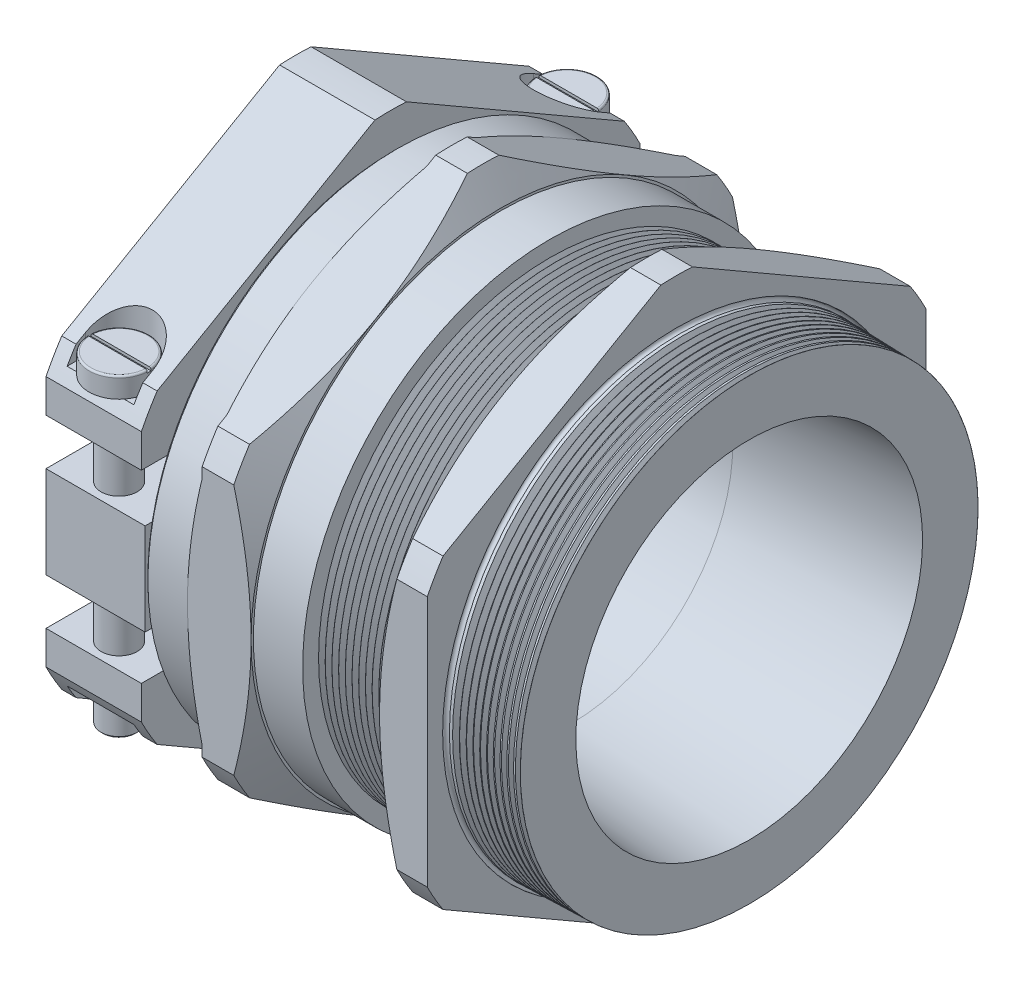
from build123d import *

# Parameters (mm, degrees)
SKETCH1_W            = 13.0175
SKETCH1_H            = 16.14932
SKETCH2_OUTSIDE_W    = 103.11
SKETCH2_OUTSIDE_H    = 103.11
CUT_EXTRUDE1_DEPTH   = 52.0446
SKETCH13_OUTSIDE_W   = 154.302
SKETCH13_OUTSIDE_H   = 162.47
SKETCH13_OUTSIDE_R   = 34.036
CUT1_DEPTH           = 17.41475
CUT1_DRAFT           = 60
SKETCH14_OUTSIDE_W   = 194.398
SKETCH14_OUTSIDE_H   = 202.566
SKETCH14_OUTSIDE_R   = 34.036
CUT2_DEPTH           = 28.989388889
CUT2_DRAFT           = -60
SKETCH15_OUTSIDE_W   = 100.904
SKETCH15_OUTSIDE_H   = 109.072
SKETCH15_OUTSIDE_R   = 34.036
CUT3_DEPTH           = 2
CUT3_DRAFT           = -60
CHAMFER1_SIZE        = 0.381
SKETCH3_W            = 68.072
SKETCH3_H            = 25.1968
CUT_EXTRUDE2_DEPTH   = 13.0175
EXTRUDE1_DEPTH       = 13.5255
CUT_EXTRUDE3_DEPTH   = 20.22272
MIRROR2_COPY_1_DEPTH = 20.22272
SKETCH6_R            = 4.1005125
EXTRUDE2_DEPTH       = 2.757269
SKETCH7_R            = 2.4603075
EXTRUDE3_DEPTH       = 34.995555556
CUT_EXTRUDE4_DEPTH   = 0.381
FILLET1_R            = 0.254
FILLET1_OF_MIRROR3_R = 0.254
LPATTERN1_COUNT      = 12
LPATTERN1_PITCH      = 0.9144
LPATTERN2_COUNT      = 10
LPATTERN2_PITCH      = 0.9144
SKETCH17_W           = 5.023555556
SKETCH17_H           = 6.5913
SKETCH16_R           = 0.4445
CHAMFER2_SIZE        = 0.254


with BuildPart() as part:
    # Sketch1 → Revolve1 (revolve)
    with BuildSketch(Plane.XY, mode=Mode.PRIVATE) as revolve1_sk:
        Polygon((24.21255, 23.664106431), (24.21255, 31.237267383), (14.33195, 31.496), (14.33195, 31.5468), (14.30655, 31.5468), (14.30655, 38.12032), (7.7978, 38.12032), (7.7978, 31.5468), (-3.024716667, 31.5468), (-3.024716667, 33.7185), (-9.748661111, 33.7185), (-9.748661111, 38.12032), (-18.426994444, 38.12032), (-18.426994444, 34.036), (-24.21255, 34.036), (-24.21255, 28.5623), (-18.426994444, 28.5623), (-18.426994444, 21.971), (0, 21.971), align=None)
        with Locations((-31.2293, 30.04566)):
            Rectangle(SKETCH1_W, SKETCH1_H)
    revolve(revolve1_sk.sketch.rotate(Axis((-81.490075188, 0, 0), (1, 0, 0)), 180), axis=Axis((-81.490075188, 0, 0), (1, 0, 0)))  # turned: the seam where the file's is

    # Sketch2 outside → Cut-Extrude1 (cut)
    with BuildSketch(Plane(origin=(14.30655, 0, 0), x_dir=(0, 0, -1), z_dir=(1, 0, 0))):
        Rectangle(SKETCH2_OUTSIDE_W, SKETCH2_OUTSIDE_H)
        with BuildLine():
            Line((-2.150850789, 38.059593243), (-31.885149211, 20.892488044))
            ThreePointArc((-31.885149211, 20.892488044), (-33.01316552, 19.06016), (-34.036, 17.167105199))
            Line((-34.036, 17.167105199), (-34.036, -17.167105199))
            ThreePointArc((-34.036, -17.167105199), (-33.01316552, -19.06016), (-31.885149211, -20.892488044))
            Line((-31.885149211, -20.892488044), (-2.150850789, -38.059593243))
            ThreePointArc((-2.150850789, -38.059593243), (0, -38.12032), (2.150850789, -38.059593243))
            Line((2.150850789, -38.059593243), (31.885149211, -20.892488044))
            ThreePointArc((31.885149211, -20.892488044), (33.01316552, -19.06016), (34.036, -17.167105199))
            Line((34.036, -17.167105199), (34.036, 17.167105199))
            ThreePointArc((34.036, 17.167105199), (33.01316552, 19.06016), (31.885149211, 20.892488044))
            Line((31.885149211, 20.892488044), (2.150850789, 38.059593243))
            ThreePointArc((2.150850789, 38.059593243), (0, 38.12032), (-2.150850789, 38.059593243))
        make_face(mode=Mode.SUBTRACT)
    extrude(amount=-CUT_EXTRUDE1_DEPTH, mode=Mode.SUBTRACT)


with BuildPart() as cut1_tool:
    # Sketch13 outside → Cut1 (with draft: the straight prism first)
    with BuildSketch(Plane(origin=(7.7978, 0, 0), x_dir=(0, 0, -1), z_dir=(1, 0, 0))):
        Rectangle(SKETCH13_OUTSIDE_W, SKETCH13_OUTSIDE_H)
        with Locations(Location((0, 0, 0), (0, 0, 270))):  # turned: the seam where the file's is
            Circle(SKETCH13_OUTSIDE_R, mode=Mode.SUBTRACT)
    extrude(amount=CUT1_DEPTH)
    # Cut1: the draft: its side faces are tilted about the plane it starts from
    cut1_sides = [cut1_tool.faces().sort_by_distance(p)[0] for p in [
        (16.505175, -81.235, 0),
        (16.505175, 0, -77.151),
        (16.505175, 81.235, 0),
        (16.505175, 0, 77.151),
        (16.505175, 34.036, 0),
    ]]
    draft(cut1_sides, Plane(origin=(7.7978, 0, 0), x_dir=(0, 0, -1), z_dir=(1, 0, 0)), CUT1_DRAFT)


with BuildPart() as part_1:
    add(part.part)

    # Cut1: cut by cut1_tool
    add(cut1_tool.part, mode=Mode.SUBTRACT)


with BuildPart() as cut2_tool:
    # Sketch14 outside → Cut2 (with draft: the straight prism first)
    with BuildSketch(Plane(origin=(-9.748661111, 0, 0), x_dir=(0, 0, -1), z_dir=(1, 0, 0))):
        Rectangle(SKETCH14_OUTSIDE_W, SKETCH14_OUTSIDE_H)
        with Locations(Location((0, 0, 0), (0, 0, 270))):  # turned: the seam where the file's is
            Circle(SKETCH14_OUTSIDE_R, mode=Mode.SUBTRACT)
    extrude(amount=-CUT2_DEPTH)
    # Cut2: the draft: its side faces are tilted about the plane it starts from
    cut2_sides = [cut2_tool.faces().sort_by_distance(p)[0] for p in [
        (-24.243355556, -101.283, 0),
        (-24.243355556, 0, -97.199),
        (-24.243355556, 101.283, 0),
        (-24.243355556, 0, 97.199),
        (-24.243355556, 34.036, 0),
    ]]
    draft(cut2_sides, Plane(origin=(-9.748661111, 0, 0), x_dir=(0, 0, -1), z_dir=(1, 0, 0)), CUT2_DRAFT)


with BuildPart() as part_2:
    add(part_1.part)

    # Cut2: cut by cut2_tool
    add(cut2_tool.part, mode=Mode.SUBTRACT)


with BuildPart() as cut3_tool:
    # Sketch15 outside → Cut3 (with draft: the straight prism first)
    with BuildSketch(Plane.ZY.offset(18.426994444)):
        Rectangle(SKETCH15_OUTSIDE_W, SKETCH15_OUTSIDE_H)
        with Locations(Location((0, 0, 0), (0, 0, 270))):  # turned: the seam where the file's is
            Circle(SKETCH15_OUTSIDE_R, mode=Mode.SUBTRACT)
    extrude(amount=-CUT3_DEPTH)
    # Cut3: the draft: its side faces are tilted about the plane it starts from
    cut3_sides = [cut3_tool.faces().sort_by_distance(p)[0] for p in [
        (-17.426994444, -54.536, 0),
        (-17.426994444, 0, 50.452),
        (-17.426994444, 54.536, 0),
        (-17.426994444, 0, -50.452),
        (-17.426994444, 34.036, 0),
    ]]
    draft(cut3_sides, Plane.ZY.offset(18.426994444), CUT3_DRAFT)


with BuildPart() as part_3:
    add(part_2.part)

    # Cut3: cut by cut3_tool
    add(cut3_tool.part, mode=Mode.SUBTRACT)

    # Chamfer1
    chamfer1_edges = [part_3.edges().sort_by_distance(p)[0] for p in [
        (-24.21255, 34.036, 0),
    ]]
    chamfer(chamfer1_edges, length=CHAMFER1_SIZE)

    # Sketch3 → Cut-Extrude2 (cut)
    with BuildSketch(Plane.ZY.offset(37.73805)):
        Rectangle(SKETCH3_W, SKETCH3_H)
    extrude(amount=-CUT_EXTRUDE2_DEPTH, mode=Mode.SUBTRACT)

    # Sketch4 → Extrude1 (add)
    with BuildSketch(Plane.ZY.offset(24.21255)):
        with BuildLine():
            Line((34.036, 6.277428571), (21.055135514, 6.277428571))
            ThreePointArc((21.055135514, 6.277428571), (21.971, 0), (21.055135514, -6.277428571))
            Line((21.055135514, -6.277428571), (34.036, -6.277428571))
            Line((34.036, -6.277428571), (34.036, 6.277428571))
        make_face()
        with BuildLine():
            Line((-34.036, -6.277428571), (-21.055135514, -6.277428571))
            ThreePointArc((-21.055135514, -6.277428571), (-21.971, 0), (-21.055135514, 6.277428571))
            Line((-21.055135514, 6.277428571), (-34.036, 6.277428571))
            Line((-34.036, 6.277428571), (-34.036, -6.277428571))
        make_face()
    extrude(amount=EXTRUDE1_DEPTH)

    # Sketch5 → Cut-Extrude3 (cut, through all)
    with BuildSketch(Plane(origin=(0, -18.8976, 0), x_dir=(1, 0, 0), z_dir=(0, 1, 0))):
        with BuildLine():
            Line((-35.785425, -30.564666667), (-35.785425, -34.036))
            Line((-35.785425, -34.036), (-26.673175, -34.036))
            Line((-26.673175, -34.036), (-26.673175, -30.564666667))
            ThreePointArc((-26.673175, -30.564666667), (-31.2293, -26.008541667), (-35.785425, -30.564666667))
        make_face()
    cut_extrude3 = extrude(amount=-CUT_EXTRUDE3_DEPTH, mode=Mode.SUBTRACT)

    # Mirror1: Cut-Extrude3 across plane
    add(cut_extrude3.mirror(Plane.ZX), mode=Mode.SUBTRACT)

    # Mirror2: Cut-Extrude3 across plane
    add(cut_extrude3.mirror(Plane.XY), mode=Mode.SUBTRACT)

    # Mirror2 copy 1 sketch → Mirror2 copy 1 (cut, through all)
    with BuildSketch(Plane.XZ.offset(-18.8976)):
        with BuildLine():
            Line((-35.785425, -30.564666667), (-35.785425, -34.036))
            Line((-35.785425, -34.036), (-26.673175, -34.036))
            Line((-26.673175, -34.036), (-26.673175, -30.564666667))
            ThreePointArc((-26.673175, -30.564666667), (-31.2293, -26.008541667), (-35.785425, -30.564666667))
        make_face()
    extrude(amount=-MIRROR2_COPY_1_DEPTH, mode=Mode.SUBTRACT)

    # Sketch7 → Extrude3 (add)
    with BuildSketch(Plane(origin=(0, 12.5984, 0), x_dir=(-1, 0, 0), z_dir=(0, 1, 0))):
        with Locations((31.2293, 30.564666667)):
            Circle(SKETCH7_R)
    extrude3 = extrude(amount=-EXTRUDE3_DEPTH)


with BuildPart() as body_2:
    # Sketch6 → Extrude2 (new body)
    with BuildSketch(Plane.XZ.offset(-18.8976)):
        with Locations(Location((-31.2293, 30.564666667, 0), (0, 0, 270))):  # turned: the seam where the file's is
            Circle(SKETCH6_R)
    extrude2 = extrude(amount=-EXTRUDE2_DEPTH)

    # Sketch8 → Cut-Extrude4 (cut)
    with BuildSketch(Plane(origin=(0, 21.654868997, 0), x_dir=(-1, 0, 0), z_dir=(0, 1, 0))):
        with BuildLine():
            Line((27.136661882, 30.818666667), (35.321938118, 30.818666667))
            ThreePointArc((35.321938118, 30.818666667), (35.3298125, 30.564666667), (35.321938118, 30.310666667))
            Line((35.321938118, 30.310666667), (27.136661882, 30.310666667))
            ThreePointArc((27.136661882, 30.310666667), (27.1287875, 30.564666667), (27.136661882, 30.818666667))
        make_face()
    cut_extrude4 = extrude(amount=-CUT_EXTRUDE4_DEPTH, mode=Mode.SUBTRACT)

    # Fillet1
    fillet1_edges = [body_2.edges().sort_by_distance(p)[0] for p in [
        (-31.2293, 21.654869, 34.665179167),
        (-28.421037852, 21.654869, 27.576713108),
    ]]
    fillet(fillet1_edges, radius=FILLET1_R)


with BuildPart() as part_4:
    add(part_3.part)

    # Mirror3: Extrude2, Extrude3, Cut-Extrude4 across plane
    add(extrude2.mirror(Plane.XY))
    add(extrude3.mirror(Plane.XY))
    add(cut_extrude4.mirror(Plane.XY), mode=Mode.SUBTRACT)

    # Fillet1 of Mirror3
    fillet1_of_mirror3_edges = [part_4.edges().sort_by_distance(p)[0] for p in [
        (-31.2293, 21.654869, -34.665179167),
        (-28.421037852, 21.654869, -27.576713108),
    ]]
    fillet(fillet1_of_mirror3_edges, radius=FILLET1_OF_MIRROR3_R)

    # Sketch11 → Cut-Revolve1 (revolve, cut)
    with BuildSketch(Plane.XY, mode=Mode.PRIVATE) as cut_revolve1_sk:
        Polygon((-3.024716667, 31.5468), (-2.121931533, 31.5468), (-2.5733241, 30.76496514), align=None)
    cut_revolve1 = revolve(cut_revolve1_sk.sketch.rotate(Axis((-25.418933975, 0, 0), (1, 0, 0)), 180), axis=Axis((-25.418933975, 0, 0), (1, 0, 0)), mode=Mode.SUBTRACT)  # turned: the seam where the file's is

    # LPattern1: Cut-Revolve1 ×12
    with Locations(*[(i * LPATTERN1_PITCH, 0, 0) for i in range(1, LPATTERN1_COUNT)]):
        add(cut_revolve1, mode=Mode.SUBTRACT)

    # Sketch12 → Cut-Revolve2 (revolve, cut)
    with BuildSketch(Plane.XY, mode=Mode.PRIVATE) as cut_revolve2_sk:
        Polygon((15.19555, 31.473385838), (16.098851067, 31.449732067), (15.654028789, 30.679277281), align=None)
    cut_revolve2 = revolve(cut_revolve2_sk.sketch.rotate(Axis((-81.490075188, 0, 0), (1, 0, 0)), 90), axis=Axis((-81.490075188, 0, 0), (1, 0, 0)), mode=Mode.SUBTRACT)  # turned: the seam where the file's is

    # LPattern2: Cut-Revolve2 ×10
    with Locations(*[(i * LPATTERN2_PITCH, 0, 0) for i in range(1, LPATTERN2_COUNT)]):
        add(cut_revolve2, mode=Mode.SUBTRACT)

    # Sketch16 → Cut-Revolve3 (revolve, cut)
    with BuildSketch(Plane.XY):
        with Locations((14.33195, -31.496)):
            Circle(SKETCH16_R)
    revolve(axis=Axis((-3.381468426, 0, 0), (1, 0, 0)), mode=Mode.SUBTRACT)

    # Chamfer2
    chamfer2_edges = [part_4.edges().sort_by_distance(p)[0] for p in [
        (-28.7689925, -22.397155556, 30.564666667),
        (-28.7689925, -22.397155556, -30.564666667),
    ]]
    chamfer(chamfer2_edges, length=CHAMFER2_SIZE)


with BuildPart() as body_3:
    # Sketch17 → Revolve3 (revolve)
    with BuildSketch(Plane.XY, mode=Mode.PRIVATE) as revolve3_sk:
        with Locations((-20.938772222, 25.26665)):
            Rectangle(SKETCH17_W, SKETCH17_H)
    revolve(revolve3_sk.sketch.rotate(Axis((13.860017965, 0, 0), (-1, 0, 0)), 180), axis=Axis((13.860017965, 0, 0), (-1, 0, 0)))  # turned: the seam where the file's is


solid = Compound([body_2.part, part_4.part, body_3.part])
